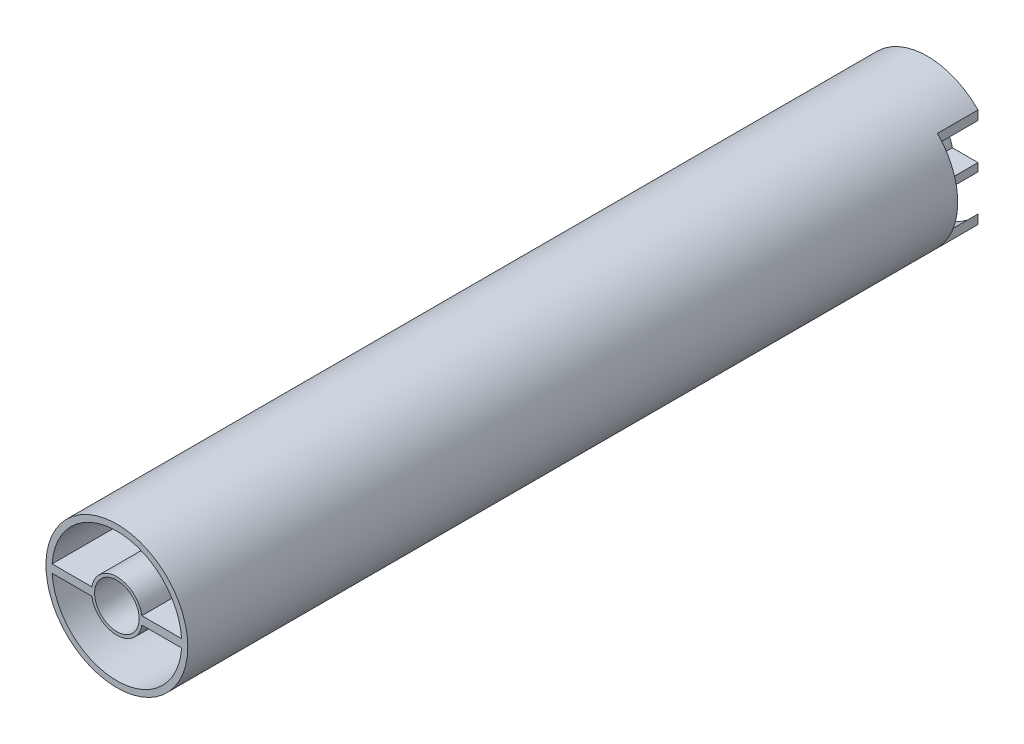
from build123d import *

# Parameters (mm, degrees)
SKETCH2_R                       = 17.5
SKETCH2_R_2                     = 5.5
SHELL_DEPTH                     = 200
SKETCH13_R                      = 16
SKETCH13_R_2                    = 6.25
SKETCH13_R_3                    = 4
INNERPARTITION_DEPTH            = 2.5
EASIERASSEMBLY_SHELLSTUDS_DEPTH = 10


with BuildPart() as part:
    # Sketch2 → Shell (new body)
    with BuildSketch(Plane.XY):
        Circle(SKETCH2_R)
        with BuildLine():
            Line((15.968719423, 1), (6.16948134, 1))
            ThreePointArc((6.16948134, 1), (0, 6.25), (-6.16948134, 1))
            Line((-6.16948134, 1), (-15.968719423, 1))
            ThreePointArc((-15.968719423, 1), (0, 16), (15.968719423, 1))
        make_face(mode=Mode.SUBTRACT)
        with BuildLine():
            ThreePointArc((-6.16948134, -1), (0, -6.25), (6.16948134, -1))
            Line((6.16948134, -1), (15.968719423, -1))
            ThreePointArc((15.968719423, -1), (0, -16), (-15.968719423, -1))
            Line((-15.968719423, -1), (-6.16948134, -1))
        make_face(mode=Mode.SUBTRACT)
        Circle(SKETCH2_R_2, mode=Mode.SUBTRACT)
    extrude(amount=SHELL_DEPTH)

    # Sketch13 → InnerPartition (add, symmetric)
    with BuildSketch(Plane.XY.offset(150)):
        Circle(SKETCH13_R)
        Circle(SKETCH13_R_2, mode=Mode.SUBTRACT)
        with Locations((0, 11.125)):
            Circle(SKETCH13_R_3, mode=Mode.SUBTRACT)
        with Locations((0, -11.125)):
            Circle(SKETCH13_R_3, mode=Mode.SUBTRACT)
    extrude(amount=INNERPARTITION_DEPTH, both=True)

    # Sketch2_18 → EasierAssembly_ShellStuds (cut)
    with BuildSketch(Plane.XY):
        with BuildLine():
            Line((12.5, 9.987492178), (12.5, 1))
            Line((12.5, 1), (15.968719423, 1))
            ThreePointArc((15.968719423, 1), (14.92684663, 5.76101117), (12.5, 9.987492178))
        make_face()
        with BuildLine():
            Line((-15.968719423, 1), (-12.5, 1))
            Line((-12.5, 1), (-12.5, 9.987492178))
            ThreePointArc((-12.5, 9.987492178), (-14.92684663, 5.76101117), (-15.968719423, 1))
        make_face()
        with BuildLine():
            ThreePointArc((-15.968719423, -1), (-14.92684663, -5.76101117), (-12.5, -9.987492178))
            Line((-12.5, -9.987492178), (-12.5, -1))
            Line((-12.5, -1), (-15.968719423, -1))
        make_face()
        with BuildLine():
            Line((12.5, -1), (12.5, -9.987492178))
            ThreePointArc((12.5, -9.987492178), (14.92684663, -5.76101117), (15.968719423, -1))
            Line((15.968719423, -1), (12.5, -1))
        make_face()
        with BuildLine():
            Line((12.5, 1), (12.5, -1))
            Line((12.5, -1), (15.968719423, -1))
            ThreePointArc((15.968719423, -1), (15.992177944, -0.500244559), (16, 0))
            ThreePointArc((16, 0), (15.992177944, 0.500244559), (15.968719423, 1))
            Line((15.968719423, 1), (12.5, 1))
        make_face()
        with BuildLine():
            Line((-15.968719423, -1), (-12.5, -1))
            Line((-12.5, -1), (-12.5, 1))
            Line((-12.5, 1), (-15.968719423, 1))
            ThreePointArc((-15.968719423, 1), (-16, 0), (-15.968719423, -1))
        make_face()
        with BuildLine():
            Line((-12.5, -12.247448714), (-12.5, -9.987492178))
            ThreePointArc((-12.5, -9.987492178), (-14.92684663, -5.76101117), (-15.968719423, -1))
            ThreePointArc((-15.968719423, -1), (-16, 0), (-15.968719423, 1))
            ThreePointArc((-15.968719423, 1), (-14.92684663, 5.76101117), (-12.5, 9.987492178))
            Line((-12.5, 9.987492178), (-12.5, 12.247448714))
            ThreePointArc((-12.5, 12.247448714), (-17.5, 0), (-12.5, -12.247448714))
        make_face()
        with BuildLine():
            ThreePointArc((15.968719423, -1), (14.92684663, -5.76101117), (12.5, -9.987492178))
            Line((12.5, -9.987492178), (12.5, -12.247448714))
            ThreePointArc((12.5, -12.247448714), (16.201851746, -6.614378278), (17.5, 0))
            ThreePointArc((17.5, 0), (16.201851746, 6.614378278), (12.5, 12.247448714))
            Line((12.5, 12.247448714), (12.5, 9.987492178))
            ThreePointArc((12.5, 9.987492178), (14.92684663, 5.76101117), (15.968719423, 1))
            ThreePointArc((15.968719423, 1), (15.992177944, 0.500244559), (16, 0))
            ThreePointArc((16, 0), (15.992177944, -0.500244559), (15.968719423, -1))
        make_face()
    extrude(amount=EASIERASSEMBLY_SHELLSTUDS_DEPTH, mode=Mode.SUBTRACT)


solid = part.part
